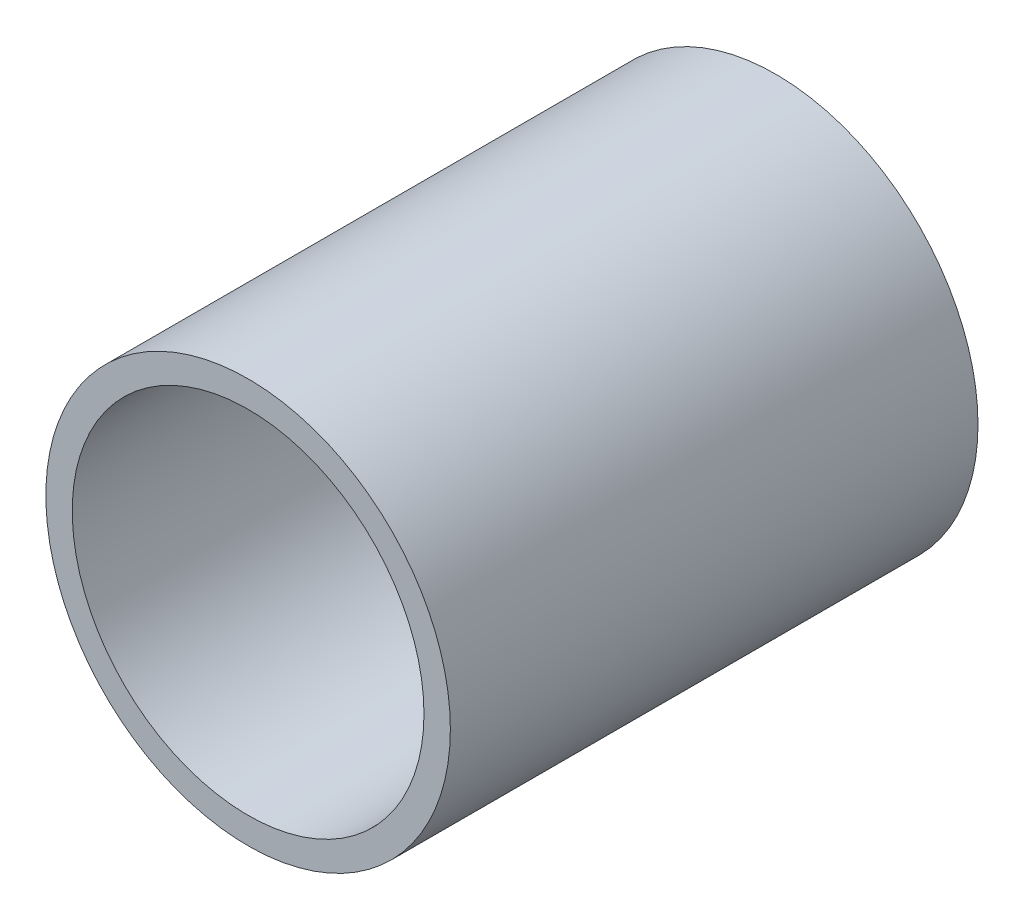
from build123d import *

# Parameters (mm, degrees)
CROQUIS1_R              = 11.5
CROQUIS1_R_2            = 10
SALIENTE_EXTRUIR1_DEPTH = 15


with BuildPart() as part:
    # Croquis1 → Saliente-Extruir1 (new body, symmetric)
    with BuildSketch(Plane.XY):
        Circle(CROQUIS1_R)
        Circle(CROQUIS1_R_2, mode=Mode.SUBTRACT)
    extrude(amount=SALIENTE_EXTRUIR1_DEPTH, both=True)


solid = part.part
